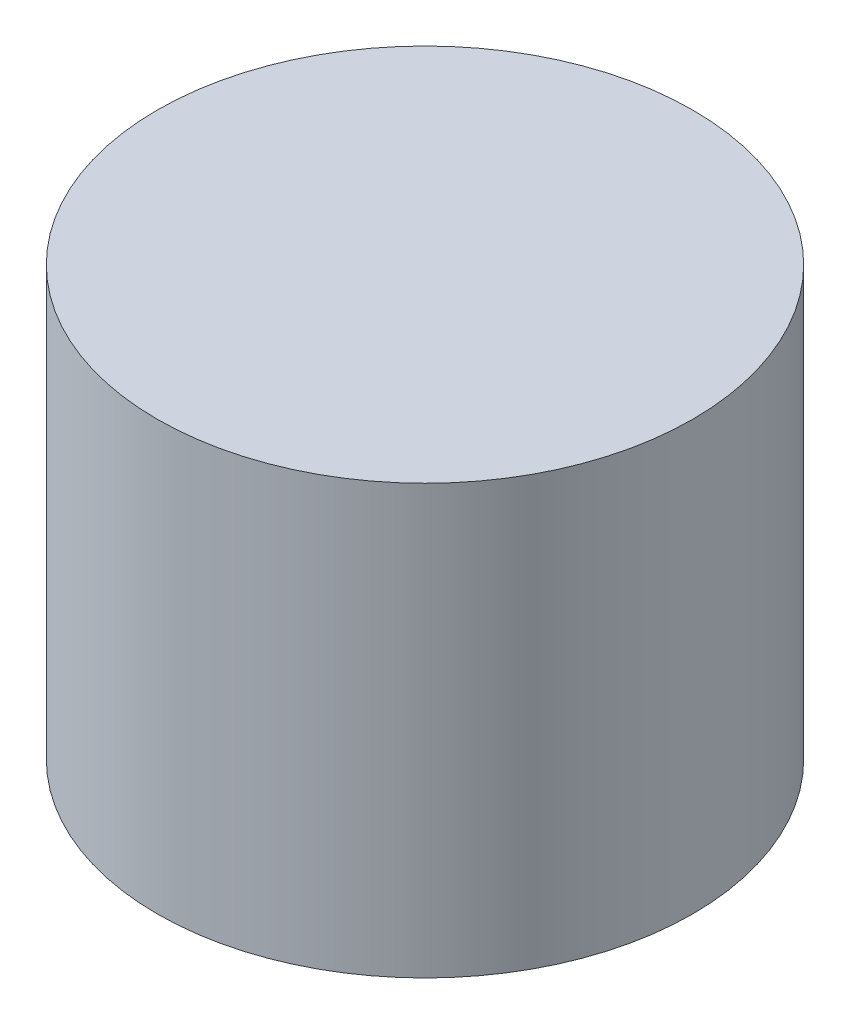
from build123d import *

# Parameters (mm, degrees)
SKETCH1_R           = 3
BOSS_EXTRUDE1_DEPTH = 4.8


with BuildPart() as part:
    # Sketch1 → Boss-Extrude1 (new body)
    with BuildSketch(Plane(origin=(0, 0, 0), x_dir=(1, 0, 0), z_dir=(0, 1, 0))):
        with Locations(Location((0, 0, 0), (0, 0, 270))):  # turned: the seam where the file's is
            Circle(SKETCH1_R)
    extrude(amount=BOSS_EXTRUDE1_DEPTH)


solid = part.part
